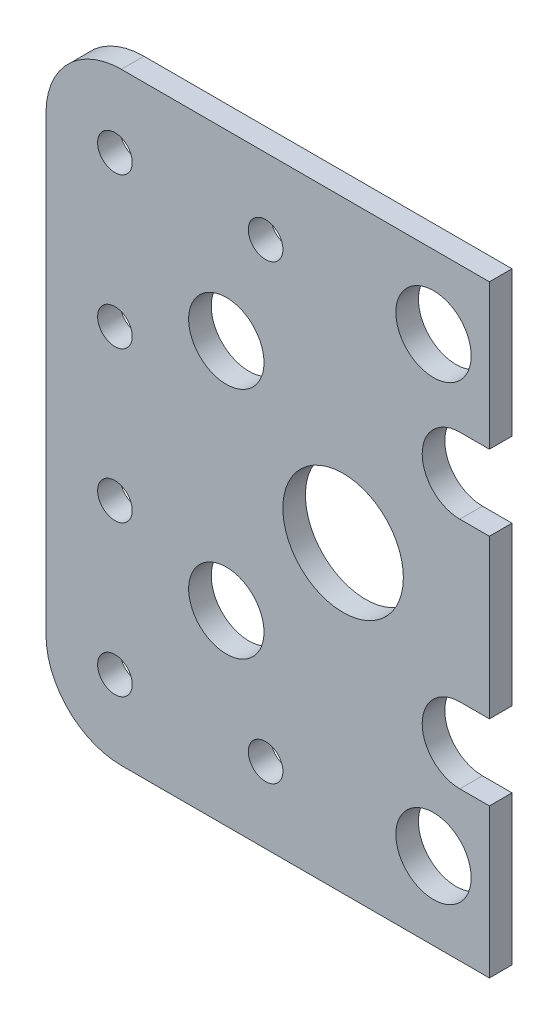
from build123d import *

# Parameters (mm, degrees)
SKETCH1_R           = 2.3
SKETCH1_R_2         = 5
SKETCH1_R_3         = 8
BOSS_EXTRUDE1_DEPTH = 3


with BuildPart() as part:
    # Sketch1 → Boss-Extrude1 (new body)
    with BuildSketch(Plane.XY):
        with BuildLine():
            Line((157.960700719, -71.866196008), (165.380720324, -71.866196008))
            Line((165.380720324, -71.866196008), (165.380720324, -91.114221831))
            Line((165.380720324, -91.114221831), (161.460700719, -91.114221831))
            ThreePointArc((161.460700719, -91.114221831), (156.460700719, -96.114221831), (161.460700719, -101.114221831))
            Line((161.460700719, -101.114221831), (165.380720324, -101.114221831))
            Line((165.380720324, -101.114221831), (165.380720324, -122.114221831))
            Line((165.380720324, -122.114221831), (161.460700719, -122.114221831))
            ThreePointArc((161.460700719, -122.114221831), (156.460700719, -127.114221831), (161.460700719, -132.114221831))
            Line((161.460700719, -132.114221831), (165.380720324, -132.114221831))
            Line((165.380720324, -132.114221831), (165.380720324, -151.896756479))
            Line((165.380720324, -151.896756479), (157.960700719, -151.896756479))
            Line((157.960700719, -151.896756479), (116.525823666, -151.896756479))
            ThreePointArc((116.525823666, -151.896756479), (109.454755854, -148.967824291), (106.525823666, -141.896756479))
            Line((106.525823666, -141.896756479), (106.525823666, -81.866196008))
            ThreePointArc((106.525823666, -81.866196008), (109.454755854, -74.795128196), (116.525823666, -71.866196008))
            Line((116.525823666, -71.866196008), (157.960700719, -71.866196008))
        make_face()
        with Locations((115.674612816, -101.866196008)):
            Circle(SKETCH1_R, mode=Mode.SUBTRACT)
        with Locations((115.674612816, -121.866196008)):
            Circle(SKETCH1_R, mode=Mode.SUBTRACT)
        with Locations((135.674612816, -141.866196008)):
            Circle(SKETCH1_R, mode=Mode.SUBTRACT)
        with Locations((135.674612816, -81.866196008)):
            Circle(SKETCH1_R, mode=Mode.SUBTRACT)
        with Locations((115.674612816, -81.866196008)):
            Circle(SKETCH1_R, mode=Mode.SUBTRACT)
        with Locations((115.674612816, -141.866196008)):
            Circle(SKETCH1_R, mode=Mode.SUBTRACT)
        with Locations((130.460700719, -96.114221831)):
            Circle(SKETCH1_R_2, mode=Mode.SUBTRACT)
        with Locations((145.960700719, -111.591712302)):
            Circle(SKETCH1_R_3, mode=Mode.SUBTRACT)
        with Locations((130.460700719, -127.114221831)):
            Circle(SKETCH1_R_2, mode=Mode.SUBTRACT)
        with Locations((157.960700719, -81.591712302)):
            Circle(SKETCH1_R_2, mode=Mode.SUBTRACT)
        with Locations((157.960700719, -141.591712302)):
            Circle(SKETCH1_R_2, mode=Mode.SUBTRACT)
    extrude(amount=BOSS_EXTRUDE1_DEPTH)


solid = part.part
